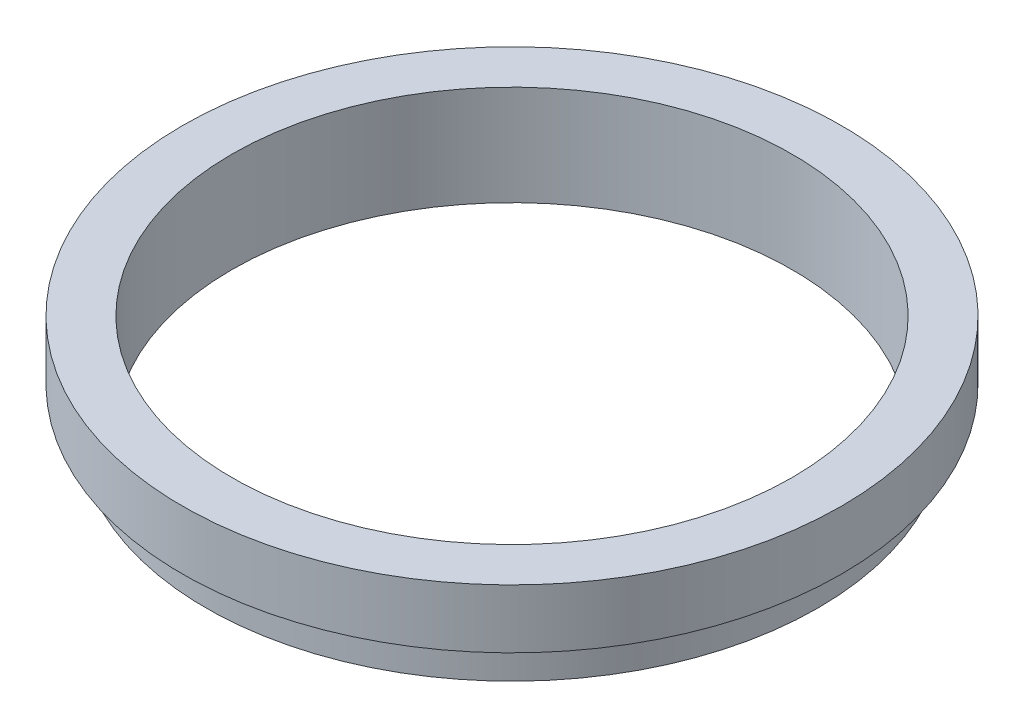
from build123d import *


with BuildPart() as part:
    # 草图1 → 旋转1 (revolve)
    with BuildSketch(Plane.XY, mode=Mode.PRIVATE) as revolve_1_sk:
        Polygon((23.8, -0.545464411), (23.8, 7.954535589), (28, 7.954535589), (28, 2.954535589), (25.4, 2.954535589), (25.4, 1.954535589), (26, 1.954535589), (26, -0.545464411), align=None)
    revolve(revolve_1_sk.sketch.rotate(Axis((0, 16.886018237, 0), (0, -1, 0)), 180), axis=Axis((0, 16.886018237, 0), (0, -1, 0)))  # turned: the seam where the file's is


solid = part.part
